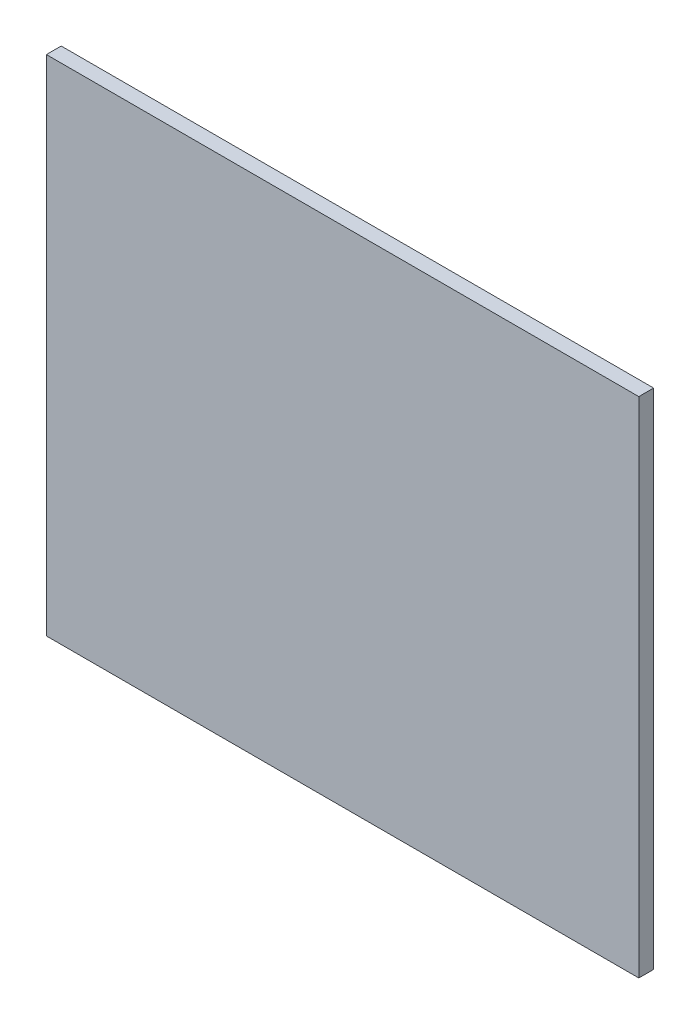
from build123d import *

# Parameters (mm, degrees)
ESBO_O1_W                = 39.98
ESBO_O1_H                = 33.98
RESSALTO_EXTRUS_O1_DEPTH = 1


with BuildPart() as part:
    # Esboço1 → Ressalto-extrusão1 (new body)
    with BuildSketch(Plane.XY):
        with Locations((19.99, 16.99)):
            Rectangle(ESBO_O1_W, ESBO_O1_H)
    extrude(amount=RESSALTO_EXTRUS_O1_DEPTH)


solid = part.part
